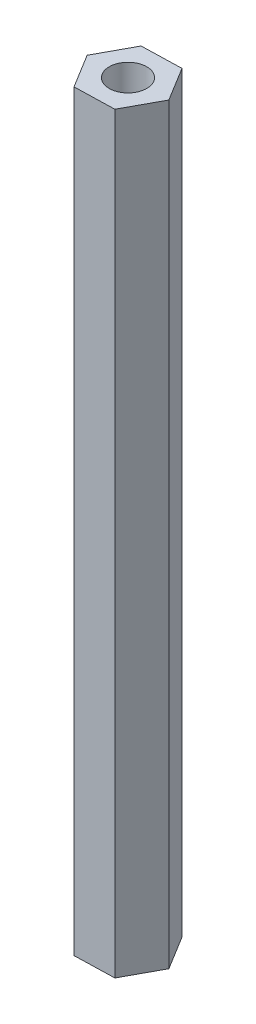
from build123d import *

# Parameters (mm, degrees)
EXTRUDE_1_DEPTH     = 60
SKETCH_2_R          = 1.5
CUT_EXTRUDE_1_DEPTH = 10
SKETCH_3_R          = 1.5
CUT_EXTRUDE_2_DEPTH = 10


with BuildPart() as part:
    # Эскиз1 → Бобышка-Вытянуть1 (new body)
    with BuildSketch(Plane(origin=(0, 0, 0), x_dir=(1, 0, 0), z_dir=(0, 1, 0))):
        Polygon((-1.514417704, -2.79103428), (1.659897738, -2.707041343), (3.174315441, 0.083992937), (1.514417704, 2.79103428), (-1.659897738, 2.707041343), (-3.174315441, -0.083992937), align=None)
    extrude(amount=EXTRUDE_1_DEPTH)

    # Эскиз2 → Вырез-Вытянуть1 (cut)
    with BuildSketch(Plane(origin=(0, 60, 0), x_dir=(1, 0, 0), z_dir=(0, 1, 0))):
        Circle(SKETCH_2_R)
    extrude(amount=-CUT_EXTRUDE_1_DEPTH, mode=Mode.SUBTRACT)

    # Эскиз3 → Вырез-Вытянуть2 (cut)
    with BuildSketch(Plane.XZ):
        Circle(SKETCH_3_R)
    extrude(amount=-CUT_EXTRUDE_2_DEPTH, mode=Mode.SUBTRACT)


solid = part.part
